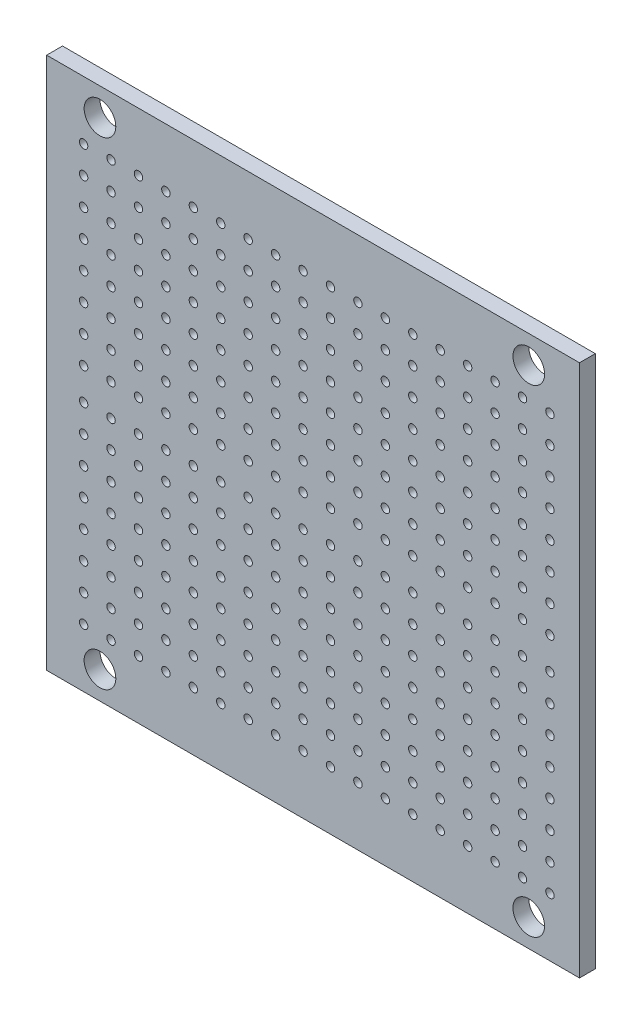
from build123d import *

# Parameters (mm, degrees)
SKETCH1_W           = 50.5
SKETCH1_H           = 50.5
SKETCH1_R           = 1.5
SKETCH1_R_2         = 0.4
BOSS_EXTRUDE1_DEPTH = 1.5
SCALE4_SCALE        = 1.485


with BuildPart() as part:
    # Sketch1 → Boss-Extrude1 (new body)
    with BuildSketch(Plane.XY):
        with Locations((0.25, 0)):
            Rectangle(SKETCH1_W, SKETCH1_H)
        with Locations((-19.95, 22.65)):
            Circle(SKETCH1_R, mode=Mode.SUBTRACT)
        with Locations((20.692322913, 22.65)):
            Circle(SKETCH1_R, mode=Mode.SUBTRACT)
        with Locations((22.7, 19.71)):
            Circle(SKETCH1_R_2, mode=Mode.SUBTRACT)
        with Locations((20.1, 19.71)):
            Circle(SKETCH1_R_2, mode=Mode.SUBTRACT)
        with Locations((17.5, 19.71)):
            Circle(SKETCH1_R_2, mode=Mode.SUBTRACT)
        with Locations((14.9, 19.71)):
            Circle(SKETCH1_R_2, mode=Mode.SUBTRACT)
        with Locations((12.3, 19.71)):
            Circle(SKETCH1_R_2, mode=Mode.SUBTRACT)
        with Locations((9.7, 19.71)):
            Circle(SKETCH1_R_2, mode=Mode.SUBTRACT)
        with Locations((7.1, 19.71)):
            Circle(SKETCH1_R_2, mode=Mode.SUBTRACT)
        with Locations((4.5, 19.71)):
            Circle(SKETCH1_R_2, mode=Mode.SUBTRACT)
        with Locations((1.9, 19.71)):
            Circle(SKETCH1_R_2, mode=Mode.SUBTRACT)
        with Locations((-0.7, 19.71)):
            Circle(SKETCH1_R_2, mode=Mode.SUBTRACT)
        with Locations((-3.3, 19.71)):
            Circle(SKETCH1_R_2, mode=Mode.SUBTRACT)
        with Locations((-5.9, 19.71)):
            Circle(SKETCH1_R_2, mode=Mode.SUBTRACT)
        with Locations((-8.5, 19.71)):
            Circle(SKETCH1_R_2, mode=Mode.SUBTRACT)
        with Locations((-11.1, 19.71)):
            Circle(SKETCH1_R_2, mode=Mode.SUBTRACT)
        with Locations((-13.7, 19.71)):
            Circle(SKETCH1_R_2, mode=Mode.SUBTRACT)
        with Locations((-16.3, 19.71)):
            Circle(SKETCH1_R_2, mode=Mode.SUBTRACT)
        with Locations((-18.9, 19.71)):
            Circle(SKETCH1_R_2, mode=Mode.SUBTRACT)
        with Locations((-21.5, 19.71)):
            Circle(SKETCH1_R_2, mode=Mode.SUBTRACT)
        with Locations((20.1, 17.11)):
            Circle(SKETCH1_R_2, mode=Mode.SUBTRACT)
        with Locations((17.5, 17.11)):
            Circle(SKETCH1_R_2, mode=Mode.SUBTRACT)
        with Locations((14.9, 17.11)):
            Circle(SKETCH1_R_2, mode=Mode.SUBTRACT)
        with Locations((12.3, 17.11)):
            Circle(SKETCH1_R_2, mode=Mode.SUBTRACT)
        with Locations((9.7, 17.11)):
            Circle(SKETCH1_R_2, mode=Mode.SUBTRACT)
        with Locations((7.1, 17.11)):
            Circle(SKETCH1_R_2, mode=Mode.SUBTRACT)
        with Locations((4.5, 17.11)):
            Circle(SKETCH1_R_2, mode=Mode.SUBTRACT)
        with Locations((1.9, 17.11)):
            Circle(SKETCH1_R_2, mode=Mode.SUBTRACT)
        with Locations((-0.7, 17.11)):
            Circle(SKETCH1_R_2, mode=Mode.SUBTRACT)
        with Locations((-3.3, 17.11)):
            Circle(SKETCH1_R_2, mode=Mode.SUBTRACT)
        with Locations((-5.9, 17.11)):
            Circle(SKETCH1_R_2, mode=Mode.SUBTRACT)
        with Locations((-8.5, 17.11)):
            Circle(SKETCH1_R_2, mode=Mode.SUBTRACT)
        with Locations((-11.1, 17.11)):
            Circle(SKETCH1_R_2, mode=Mode.SUBTRACT)
        with Locations((-13.7, 17.11)):
            Circle(SKETCH1_R_2, mode=Mode.SUBTRACT)
        with Locations((-16.3, 17.11)):
            Circle(SKETCH1_R_2, mode=Mode.SUBTRACT)
        with Locations((-18.9, 17.11)):
            Circle(SKETCH1_R_2, mode=Mode.SUBTRACT)
        with Locations((-21.5, 17.11)):
            Circle(SKETCH1_R_2, mode=Mode.SUBTRACT)
        with Locations((20.1, 14.51)):
            Circle(SKETCH1_R_2, mode=Mode.SUBTRACT)
        with Locations((17.5, 14.51)):
            Circle(SKETCH1_R_2, mode=Mode.SUBTRACT)
        with Locations((14.9, 14.51)):
            Circle(SKETCH1_R_2, mode=Mode.SUBTRACT)
        with Locations((12.3, 14.51)):
            Circle(SKETCH1_R_2, mode=Mode.SUBTRACT)
        with Locations((9.7, 14.51)):
            Circle(SKETCH1_R_2, mode=Mode.SUBTRACT)
        with Locations((7.1, 14.51)):
            Circle(SKETCH1_R_2, mode=Mode.SUBTRACT)
        with Locations((4.5, 14.51)):
            Circle(SKETCH1_R_2, mode=Mode.SUBTRACT)
        with Locations((1.9, 14.51)):
            Circle(SKETCH1_R_2, mode=Mode.SUBTRACT)
        with Locations((-0.7, 14.51)):
            Circle(SKETCH1_R_2, mode=Mode.SUBTRACT)
        with Locations((-3.3, 14.51)):
            Circle(SKETCH1_R_2, mode=Mode.SUBTRACT)
        with Locations((-5.9, 14.51)):
            Circle(SKETCH1_R_2, mode=Mode.SUBTRACT)
        with Locations((-8.5, 14.51)):
            Circle(SKETCH1_R_2, mode=Mode.SUBTRACT)
        with Locations((-11.1, 14.51)):
            Circle(SKETCH1_R_2, mode=Mode.SUBTRACT)
        with Locations((-13.7, 14.51)):
            Circle(SKETCH1_R_2, mode=Mode.SUBTRACT)
        with Locations((-16.3, 14.51)):
            Circle(SKETCH1_R_2, mode=Mode.SUBTRACT)
        with Locations((-18.9, 14.51)):
            Circle(SKETCH1_R_2, mode=Mode.SUBTRACT)
        with Locations((-21.5, 14.51)):
            Circle(SKETCH1_R_2, mode=Mode.SUBTRACT)
        with Locations((20.1, 11.91)):
            Circle(SKETCH1_R_2, mode=Mode.SUBTRACT)
        with Locations((17.5, 11.91)):
            Circle(SKETCH1_R_2, mode=Mode.SUBTRACT)
        with Locations((14.9, 11.91)):
            Circle(SKETCH1_R_2, mode=Mode.SUBTRACT)
        with Locations((12.3, 11.91)):
            Circle(SKETCH1_R_2, mode=Mode.SUBTRACT)
        with Locations((9.7, 11.91)):
            Circle(SKETCH1_R_2, mode=Mode.SUBTRACT)
        with Locations((7.1, 11.91)):
            Circle(SKETCH1_R_2, mode=Mode.SUBTRACT)
        with Locations((4.5, 11.91)):
            Circle(SKETCH1_R_2, mode=Mode.SUBTRACT)
        with Locations((1.9, 11.91)):
            Circle(SKETCH1_R_2, mode=Mode.SUBTRACT)
        with Locations((-0.7, 11.91)):
            Circle(SKETCH1_R_2, mode=Mode.SUBTRACT)
        with Locations((-3.3, 11.91)):
            Circle(SKETCH1_R_2, mode=Mode.SUBTRACT)
        with Locations((-5.9, 11.91)):
            Circle(SKETCH1_R_2, mode=Mode.SUBTRACT)
        with Locations((-8.5, 11.91)):
            Circle(SKETCH1_R_2, mode=Mode.SUBTRACT)
        with Locations((-11.1, 11.91)):
            Circle(SKETCH1_R_2, mode=Mode.SUBTRACT)
        with Locations((-13.7, 11.91)):
            Circle(SKETCH1_R_2, mode=Mode.SUBTRACT)
        with Locations((-16.3, 11.91)):
            Circle(SKETCH1_R_2, mode=Mode.SUBTRACT)
        with Locations((-18.9, 11.91)):
            Circle(SKETCH1_R_2, mode=Mode.SUBTRACT)
        with Locations((-21.5, 11.91)):
            Circle(SKETCH1_R_2, mode=Mode.SUBTRACT)
        with Locations((20.1, 9.31)):
            Circle(SKETCH1_R_2, mode=Mode.SUBTRACT)
        with Locations((17.5, 9.31)):
            Circle(SKETCH1_R_2, mode=Mode.SUBTRACT)
        with Locations((14.9, 9.31)):
            Circle(SKETCH1_R_2, mode=Mode.SUBTRACT)
        with Locations((12.3, 9.31)):
            Circle(SKETCH1_R_2, mode=Mode.SUBTRACT)
        with Locations((9.7, 9.31)):
            Circle(SKETCH1_R_2, mode=Mode.SUBTRACT)
        with Locations((7.1, 9.31)):
            Circle(SKETCH1_R_2, mode=Mode.SUBTRACT)
        with Locations((4.5, 9.31)):
            Circle(SKETCH1_R_2, mode=Mode.SUBTRACT)
        with Locations((1.9, 9.31)):
            Circle(SKETCH1_R_2, mode=Mode.SUBTRACT)
        with Locations((-0.7, 9.31)):
            Circle(SKETCH1_R_2, mode=Mode.SUBTRACT)
        with Locations((-3.3, 9.31)):
            Circle(SKETCH1_R_2, mode=Mode.SUBTRACT)
        with Locations((-5.9, 9.31)):
            Circle(SKETCH1_R_2, mode=Mode.SUBTRACT)
        with Locations((-8.5, 9.31)):
            Circle(SKETCH1_R_2, mode=Mode.SUBTRACT)
        with Locations((-11.1, 9.31)):
            Circle(SKETCH1_R_2, mode=Mode.SUBTRACT)
        with Locations((-13.7, 9.31)):
            Circle(SKETCH1_R_2, mode=Mode.SUBTRACT)
        with Locations((-16.3, 9.31)):
            Circle(SKETCH1_R_2, mode=Mode.SUBTRACT)
        with Locations((-18.9, 9.31)):
            Circle(SKETCH1_R_2, mode=Mode.SUBTRACT)
        with Locations((-21.5, 9.31)):
            Circle(SKETCH1_R_2, mode=Mode.SUBTRACT)
        with Locations((20.1, 6.71)):
            Circle(SKETCH1_R_2, mode=Mode.SUBTRACT)
        with Locations((17.5, 6.71)):
            Circle(SKETCH1_R_2, mode=Mode.SUBTRACT)
        with Locations((14.9, 6.71)):
            Circle(SKETCH1_R_2, mode=Mode.SUBTRACT)
        with Locations((12.3, 6.71)):
            Circle(SKETCH1_R_2, mode=Mode.SUBTRACT)
        with Locations((9.7, 6.71)):
            Circle(SKETCH1_R_2, mode=Mode.SUBTRACT)
        with Locations((7.1, 6.71)):
            Circle(SKETCH1_R_2, mode=Mode.SUBTRACT)
        with Locations((4.5, 6.71)):
            Circle(SKETCH1_R_2, mode=Mode.SUBTRACT)
        with Locations((1.9, 6.71)):
            Circle(SKETCH1_R_2, mode=Mode.SUBTRACT)
        with Locations((-0.7, 6.71)):
            Circle(SKETCH1_R_2, mode=Mode.SUBTRACT)
        with Locations((-3.3, 6.71)):
            Circle(SKETCH1_R_2, mode=Mode.SUBTRACT)
        with Locations((-5.9, 6.71)):
            Circle(SKETCH1_R_2, mode=Mode.SUBTRACT)
        with Locations((-8.5, 6.71)):
            Circle(SKETCH1_R_2, mode=Mode.SUBTRACT)
        with Locations((-11.1, 6.71)):
            Circle(SKETCH1_R_2, mode=Mode.SUBTRACT)
        with Locations((-13.7, 6.71)):
            Circle(SKETCH1_R_2, mode=Mode.SUBTRACT)
        with Locations((-16.3, 6.71)):
            Circle(SKETCH1_R_2, mode=Mode.SUBTRACT)
        with Locations((-18.9, 6.71)):
            Circle(SKETCH1_R_2, mode=Mode.SUBTRACT)
        with Locations((-21.5, 6.71)):
            Circle(SKETCH1_R_2, mode=Mode.SUBTRACT)
        with Locations((20.1, 4.11)):
            Circle(SKETCH1_R_2, mode=Mode.SUBTRACT)
        with Locations((17.5, 4.11)):
            Circle(SKETCH1_R_2, mode=Mode.SUBTRACT)
        with Locations((14.9, 4.11)):
            Circle(SKETCH1_R_2, mode=Mode.SUBTRACT)
        with Locations((12.3, 4.11)):
            Circle(SKETCH1_R_2, mode=Mode.SUBTRACT)
        with Locations((9.7, 4.11)):
            Circle(SKETCH1_R_2, mode=Mode.SUBTRACT)
        with Locations((7.1, 4.11)):
            Circle(SKETCH1_R_2, mode=Mode.SUBTRACT)
        with Locations((4.5, 4.11)):
            Circle(SKETCH1_R_2, mode=Mode.SUBTRACT)
        with Locations((1.9, 4.11)):
            Circle(SKETCH1_R_2, mode=Mode.SUBTRACT)
        with Locations((-0.7, 4.11)):
            Circle(SKETCH1_R_2, mode=Mode.SUBTRACT)
        with Locations((-3.3, 4.11)):
            Circle(SKETCH1_R_2, mode=Mode.SUBTRACT)
        with Locations((-5.9, 4.11)):
            Circle(SKETCH1_R_2, mode=Mode.SUBTRACT)
        with Locations((-8.5, 4.11)):
            Circle(SKETCH1_R_2, mode=Mode.SUBTRACT)
        with Locations((-11.1, 4.11)):
            Circle(SKETCH1_R_2, mode=Mode.SUBTRACT)
        with Locations((-13.7, 4.11)):
            Circle(SKETCH1_R_2, mode=Mode.SUBTRACT)
        with Locations((-16.3, 4.11)):
            Circle(SKETCH1_R_2, mode=Mode.SUBTRACT)
        with Locations((-18.9, 4.11)):
            Circle(SKETCH1_R_2, mode=Mode.SUBTRACT)
        with Locations((-21.5, 4.11)):
            Circle(SKETCH1_R_2, mode=Mode.SUBTRACT)
        with Locations((20.1, 1.51)):
            Circle(SKETCH1_R_2, mode=Mode.SUBTRACT)
        with Locations((17.5, 1.51)):
            Circle(SKETCH1_R_2, mode=Mode.SUBTRACT)
        with Locations((14.9, 1.51)):
            Circle(SKETCH1_R_2, mode=Mode.SUBTRACT)
        with Locations((12.3, 1.51)):
            Circle(SKETCH1_R_2, mode=Mode.SUBTRACT)
        with Locations((9.7, 1.51)):
            Circle(SKETCH1_R_2, mode=Mode.SUBTRACT)
        with Locations((7.1, 1.51)):
            Circle(SKETCH1_R_2, mode=Mode.SUBTRACT)
        with Locations((4.5, 1.51)):
            Circle(SKETCH1_R_2, mode=Mode.SUBTRACT)
        with Locations((1.9, 1.51)):
            Circle(SKETCH1_R_2, mode=Mode.SUBTRACT)
        with Locations((-0.7, 1.51)):
            Circle(SKETCH1_R_2, mode=Mode.SUBTRACT)
        with Locations((-3.3, 1.51)):
            Circle(SKETCH1_R_2, mode=Mode.SUBTRACT)
        with Locations((-5.9, 1.51)):
            Circle(SKETCH1_R_2, mode=Mode.SUBTRACT)
        with Locations((-8.5, 1.51)):
            Circle(SKETCH1_R_2, mode=Mode.SUBTRACT)
        with Locations((-11.1, 1.51)):
            Circle(SKETCH1_R_2, mode=Mode.SUBTRACT)
        with Locations((-13.7, 1.51)):
            Circle(SKETCH1_R_2, mode=Mode.SUBTRACT)
        with Locations((-16.3, 1.51)):
            Circle(SKETCH1_R_2, mode=Mode.SUBTRACT)
        with Locations((-18.9, 1.51)):
            Circle(SKETCH1_R_2, mode=Mode.SUBTRACT)
        with Locations((-21.5, 1.51)):
            Circle(SKETCH1_R_2, mode=Mode.SUBTRACT)
        with Locations((22.7, 17.11)):
            Circle(SKETCH1_R_2, mode=Mode.SUBTRACT)
        with Locations((22.7, 14.51)):
            Circle(SKETCH1_R_2, mode=Mode.SUBTRACT)
        with Locations((22.7, 11.91)):
            Circle(SKETCH1_R_2, mode=Mode.SUBTRACT)
        with Locations((22.7, 9.31)):
            Circle(SKETCH1_R_2, mode=Mode.SUBTRACT)
        with Locations((22.7, 6.71)):
            Circle(SKETCH1_R_2, mode=Mode.SUBTRACT)
        with Locations((22.7, 4.11)):
            Circle(SKETCH1_R_2, mode=Mode.SUBTRACT)
        with Locations((22.7, 1.51)):
            Circle(SKETCH1_R_2, mode=Mode.SUBTRACT)
        with Locations((22.7, -1.51)):
            Circle(SKETCH1_R_2, mode=Mode.SUBTRACT)
        with Locations((22.7, -4.11)):
            Circle(SKETCH1_R_2, mode=Mode.SUBTRACT)
        with Locations((22.7, -6.71)):
            Circle(SKETCH1_R_2, mode=Mode.SUBTRACT)
        with Locations((22.7, -9.31)):
            Circle(SKETCH1_R_2, mode=Mode.SUBTRACT)
        with Locations((22.7, -11.91)):
            Circle(SKETCH1_R_2, mode=Mode.SUBTRACT)
        with Locations((22.7, -14.51)):
            Circle(SKETCH1_R_2, mode=Mode.SUBTRACT)
        with Locations((22.7, -17.11)):
            Circle(SKETCH1_R_2, mode=Mode.SUBTRACT)
        with Locations((-21.5, -1.51)):
            Circle(SKETCH1_R_2, mode=Mode.SUBTRACT)
        with Locations((-18.9, -1.51)):
            Circle(SKETCH1_R_2, mode=Mode.SUBTRACT)
        with Locations((-16.3, -1.51)):
            Circle(SKETCH1_R_2, mode=Mode.SUBTRACT)
        with Locations((-13.7, -1.51)):
            Circle(SKETCH1_R_2, mode=Mode.SUBTRACT)
        with Locations((-11.1, -1.51)):
            Circle(SKETCH1_R_2, mode=Mode.SUBTRACT)
        with Locations((-8.5, -1.51)):
            Circle(SKETCH1_R_2, mode=Mode.SUBTRACT)
        with Locations((-5.9, -1.51)):
            Circle(SKETCH1_R_2, mode=Mode.SUBTRACT)
        with Locations((-3.3, -1.51)):
            Circle(SKETCH1_R_2, mode=Mode.SUBTRACT)
        with Locations((-0.7, -1.51)):
            Circle(SKETCH1_R_2, mode=Mode.SUBTRACT)
        with Locations((1.9, -1.51)):
            Circle(SKETCH1_R_2, mode=Mode.SUBTRACT)
        with Locations((4.5, -1.51)):
            Circle(SKETCH1_R_2, mode=Mode.SUBTRACT)
        with Locations((7.1, -1.51)):
            Circle(SKETCH1_R_2, mode=Mode.SUBTRACT)
        with Locations((9.7, -1.51)):
            Circle(SKETCH1_R_2, mode=Mode.SUBTRACT)
        with Locations((12.3, -1.51)):
            Circle(SKETCH1_R_2, mode=Mode.SUBTRACT)
        with Locations((14.9, -1.51)):
            Circle(SKETCH1_R_2, mode=Mode.SUBTRACT)
        with Locations((17.5, -1.51)):
            Circle(SKETCH1_R_2, mode=Mode.SUBTRACT)
        with Locations((20.1, -1.51)):
            Circle(SKETCH1_R_2, mode=Mode.SUBTRACT)
        with Locations((-21.5, -4.11)):
            Circle(SKETCH1_R_2, mode=Mode.SUBTRACT)
        with Locations((-18.9, -4.11)):
            Circle(SKETCH1_R_2, mode=Mode.SUBTRACT)
        with Locations((-16.3, -4.11)):
            Circle(SKETCH1_R_2, mode=Mode.SUBTRACT)
        with Locations((-13.7, -4.11)):
            Circle(SKETCH1_R_2, mode=Mode.SUBTRACT)
        with Locations((-11.1, -4.11)):
            Circle(SKETCH1_R_2, mode=Mode.SUBTRACT)
        with Locations((-8.5, -4.11)):
            Circle(SKETCH1_R_2, mode=Mode.SUBTRACT)
        with Locations((-5.9, -4.11)):
            Circle(SKETCH1_R_2, mode=Mode.SUBTRACT)
        with Locations((-3.3, -4.11)):
            Circle(SKETCH1_R_2, mode=Mode.SUBTRACT)
        with Locations((-0.7, -4.11)):
            Circle(SKETCH1_R_2, mode=Mode.SUBTRACT)
        with Locations((1.9, -4.11)):
            Circle(SKETCH1_R_2, mode=Mode.SUBTRACT)
        with Locations((4.5, -4.11)):
            Circle(SKETCH1_R_2, mode=Mode.SUBTRACT)
        with Locations((7.1, -4.11)):
            Circle(SKETCH1_R_2, mode=Mode.SUBTRACT)
        with Locations((9.7, -4.11)):
            Circle(SKETCH1_R_2, mode=Mode.SUBTRACT)
        with Locations((12.3, -4.11)):
            Circle(SKETCH1_R_2, mode=Mode.SUBTRACT)
        with Locations((14.9, -4.11)):
            Circle(SKETCH1_R_2, mode=Mode.SUBTRACT)
        with Locations((17.5, -4.11)):
            Circle(SKETCH1_R_2, mode=Mode.SUBTRACT)
        with Locations((20.1, -4.11)):
            Circle(SKETCH1_R_2, mode=Mode.SUBTRACT)
        with Locations((-21.5, -6.71)):
            Circle(SKETCH1_R_2, mode=Mode.SUBTRACT)
        with Locations((-18.9, -6.71)):
            Circle(SKETCH1_R_2, mode=Mode.SUBTRACT)
        with Locations((-16.3, -6.71)):
            Circle(SKETCH1_R_2, mode=Mode.SUBTRACT)
        with Locations((-13.7, -6.71)):
            Circle(SKETCH1_R_2, mode=Mode.SUBTRACT)
        with Locations((-11.1, -6.71)):
            Circle(SKETCH1_R_2, mode=Mode.SUBTRACT)
        with Locations((-8.5, -6.71)):
            Circle(SKETCH1_R_2, mode=Mode.SUBTRACT)
        with Locations((-5.9, -6.71)):
            Circle(SKETCH1_R_2, mode=Mode.SUBTRACT)
        with Locations((-3.3, -6.71)):
            Circle(SKETCH1_R_2, mode=Mode.SUBTRACT)
        with Locations((-0.7, -6.71)):
            Circle(SKETCH1_R_2, mode=Mode.SUBTRACT)
        with Locations((1.9, -6.71)):
            Circle(SKETCH1_R_2, mode=Mode.SUBTRACT)
        with Locations((4.5, -6.71)):
            Circle(SKETCH1_R_2, mode=Mode.SUBTRACT)
        with Locations((7.1, -6.71)):
            Circle(SKETCH1_R_2, mode=Mode.SUBTRACT)
        with Locations((9.7, -6.71)):
            Circle(SKETCH1_R_2, mode=Mode.SUBTRACT)
        with Locations((12.3, -6.71)):
            Circle(SKETCH1_R_2, mode=Mode.SUBTRACT)
        with Locations((14.9, -6.71)):
            Circle(SKETCH1_R_2, mode=Mode.SUBTRACT)
        with Locations((17.5, -6.71)):
            Circle(SKETCH1_R_2, mode=Mode.SUBTRACT)
        with Locations((20.1, -6.71)):
            Circle(SKETCH1_R_2, mode=Mode.SUBTRACT)
        with Locations((-21.5, -9.31)):
            Circle(SKETCH1_R_2, mode=Mode.SUBTRACT)
        with Locations((-18.9, -9.31)):
            Circle(SKETCH1_R_2, mode=Mode.SUBTRACT)
        with Locations((-16.3, -9.31)):
            Circle(SKETCH1_R_2, mode=Mode.SUBTRACT)
        with Locations((-13.7, -9.31)):
            Circle(SKETCH1_R_2, mode=Mode.SUBTRACT)
        with Locations((-11.1, -9.31)):
            Circle(SKETCH1_R_2, mode=Mode.SUBTRACT)
        with Locations((-8.5, -9.31)):
            Circle(SKETCH1_R_2, mode=Mode.SUBTRACT)
        with Locations((-5.9, -9.31)):
            Circle(SKETCH1_R_2, mode=Mode.SUBTRACT)
        with Locations((-3.3, -9.31)):
            Circle(SKETCH1_R_2, mode=Mode.SUBTRACT)
        with Locations((-0.7, -9.31)):
            Circle(SKETCH1_R_2, mode=Mode.SUBTRACT)
        with Locations((1.9, -9.31)):
            Circle(SKETCH1_R_2, mode=Mode.SUBTRACT)
        with Locations((4.5, -9.31)):
            Circle(SKETCH1_R_2, mode=Mode.SUBTRACT)
        with Locations((7.1, -9.31)):
            Circle(SKETCH1_R_2, mode=Mode.SUBTRACT)
        with Locations((9.7, -9.31)):
            Circle(SKETCH1_R_2, mode=Mode.SUBTRACT)
        with Locations((12.3, -9.31)):
            Circle(SKETCH1_R_2, mode=Mode.SUBTRACT)
        with Locations((14.9, -9.31)):
            Circle(SKETCH1_R_2, mode=Mode.SUBTRACT)
        with Locations((17.5, -9.31)):
            Circle(SKETCH1_R_2, mode=Mode.SUBTRACT)
        with Locations((20.1, -9.31)):
            Circle(SKETCH1_R_2, mode=Mode.SUBTRACT)
        with Locations((-21.5, -11.91)):
            Circle(SKETCH1_R_2, mode=Mode.SUBTRACT)
        with Locations((-18.9, -11.91)):
            Circle(SKETCH1_R_2, mode=Mode.SUBTRACT)
        with Locations((-16.3, -11.91)):
            Circle(SKETCH1_R_2, mode=Mode.SUBTRACT)
        with Locations((-13.7, -11.91)):
            Circle(SKETCH1_R_2, mode=Mode.SUBTRACT)
        with Locations((-11.1, -11.91)):
            Circle(SKETCH1_R_2, mode=Mode.SUBTRACT)
        with Locations((-8.5, -11.91)):
            Circle(SKETCH1_R_2, mode=Mode.SUBTRACT)
        with Locations((-5.9, -11.91)):
            Circle(SKETCH1_R_2, mode=Mode.SUBTRACT)
        with Locations((-3.3, -11.91)):
            Circle(SKETCH1_R_2, mode=Mode.SUBTRACT)
        with Locations((-0.7, -11.91)):
            Circle(SKETCH1_R_2, mode=Mode.SUBTRACT)
        with Locations((1.9, -11.91)):
            Circle(SKETCH1_R_2, mode=Mode.SUBTRACT)
        with Locations((4.5, -11.91)):
            Circle(SKETCH1_R_2, mode=Mode.SUBTRACT)
        with Locations((7.1, -11.91)):
            Circle(SKETCH1_R_2, mode=Mode.SUBTRACT)
        with Locations((9.7, -11.91)):
            Circle(SKETCH1_R_2, mode=Mode.SUBTRACT)
        with Locations((12.3, -11.91)):
            Circle(SKETCH1_R_2, mode=Mode.SUBTRACT)
        with Locations((14.9, -11.91)):
            Circle(SKETCH1_R_2, mode=Mode.SUBTRACT)
        with Locations((17.5, -11.91)):
            Circle(SKETCH1_R_2, mode=Mode.SUBTRACT)
        with Locations((20.1, -11.91)):
            Circle(SKETCH1_R_2, mode=Mode.SUBTRACT)
        with Locations((-21.5, -14.51)):
            Circle(SKETCH1_R_2, mode=Mode.SUBTRACT)
        with Locations((-18.9, -14.51)):
            Circle(SKETCH1_R_2, mode=Mode.SUBTRACT)
        with Locations((-16.3, -14.51)):
            Circle(SKETCH1_R_2, mode=Mode.SUBTRACT)
        with Locations((-13.7, -14.51)):
            Circle(SKETCH1_R_2, mode=Mode.SUBTRACT)
        with Locations((-11.1, -14.51)):
            Circle(SKETCH1_R_2, mode=Mode.SUBTRACT)
        with Locations((-8.5, -14.51)):
            Circle(SKETCH1_R_2, mode=Mode.SUBTRACT)
        with Locations((-5.9, -14.51)):
            Circle(SKETCH1_R_2, mode=Mode.SUBTRACT)
        with Locations((-3.3, -14.51)):
            Circle(SKETCH1_R_2, mode=Mode.SUBTRACT)
        with Locations((-0.7, -14.51)):
            Circle(SKETCH1_R_2, mode=Mode.SUBTRACT)
        with Locations((1.9, -14.51)):
            Circle(SKETCH1_R_2, mode=Mode.SUBTRACT)
        with Locations((4.5, -14.51)):
            Circle(SKETCH1_R_2, mode=Mode.SUBTRACT)
        with Locations((7.1, -14.51)):
            Circle(SKETCH1_R_2, mode=Mode.SUBTRACT)
        with Locations((9.7, -14.51)):
            Circle(SKETCH1_R_2, mode=Mode.SUBTRACT)
        with Locations((12.3, -14.51)):
            Circle(SKETCH1_R_2, mode=Mode.SUBTRACT)
        with Locations((14.9, -14.51)):
            Circle(SKETCH1_R_2, mode=Mode.SUBTRACT)
        with Locations((17.5, -14.51)):
            Circle(SKETCH1_R_2, mode=Mode.SUBTRACT)
        with Locations((20.1, -14.51)):
            Circle(SKETCH1_R_2, mode=Mode.SUBTRACT)
        with Locations((-21.5, -17.11)):
            Circle(SKETCH1_R_2, mode=Mode.SUBTRACT)
        with Locations((-18.9, -17.11)):
            Circle(SKETCH1_R_2, mode=Mode.SUBTRACT)
        with Locations((-16.3, -17.11)):
            Circle(SKETCH1_R_2, mode=Mode.SUBTRACT)
        with Locations((-13.7, -17.11)):
            Circle(SKETCH1_R_2, mode=Mode.SUBTRACT)
        with Locations((-11.1, -17.11)):
            Circle(SKETCH1_R_2, mode=Mode.SUBTRACT)
        with Locations((-8.5, -17.11)):
            Circle(SKETCH1_R_2, mode=Mode.SUBTRACT)
        with Locations((-5.9, -17.11)):
            Circle(SKETCH1_R_2, mode=Mode.SUBTRACT)
        with Locations((-3.3, -17.11)):
            Circle(SKETCH1_R_2, mode=Mode.SUBTRACT)
        with Locations((-0.7, -17.11)):
            Circle(SKETCH1_R_2, mode=Mode.SUBTRACT)
        with Locations((1.9, -17.11)):
            Circle(SKETCH1_R_2, mode=Mode.SUBTRACT)
        with Locations((4.5, -17.11)):
            Circle(SKETCH1_R_2, mode=Mode.SUBTRACT)
        with Locations((7.1, -17.11)):
            Circle(SKETCH1_R_2, mode=Mode.SUBTRACT)
        with Locations((9.7, -17.11)):
            Circle(SKETCH1_R_2, mode=Mode.SUBTRACT)
        with Locations((12.3, -17.11)):
            Circle(SKETCH1_R_2, mode=Mode.SUBTRACT)
        with Locations((14.9, -17.11)):
            Circle(SKETCH1_R_2, mode=Mode.SUBTRACT)
        with Locations((17.5, -17.11)):
            Circle(SKETCH1_R_2, mode=Mode.SUBTRACT)
        with Locations((20.1, -17.11)):
            Circle(SKETCH1_R_2, mode=Mode.SUBTRACT)
        with Locations((-21.5, -19.71)):
            Circle(SKETCH1_R_2, mode=Mode.SUBTRACT)
        with Locations((-18.9, -19.71)):
            Circle(SKETCH1_R_2, mode=Mode.SUBTRACT)
        with Locations((-16.3, -19.71)):
            Circle(SKETCH1_R_2, mode=Mode.SUBTRACT)
        with Locations((-13.7, -19.71)):
            Circle(SKETCH1_R_2, mode=Mode.SUBTRACT)
        with Locations((-11.1, -19.71)):
            Circle(SKETCH1_R_2, mode=Mode.SUBTRACT)
        with Locations((-8.5, -19.71)):
            Circle(SKETCH1_R_2, mode=Mode.SUBTRACT)
        with Locations((-5.9, -19.71)):
            Circle(SKETCH1_R_2, mode=Mode.SUBTRACT)
        with Locations((-3.3, -19.71)):
            Circle(SKETCH1_R_2, mode=Mode.SUBTRACT)
        with Locations((-0.7, -19.71)):
            Circle(SKETCH1_R_2, mode=Mode.SUBTRACT)
        with Locations((1.9, -19.71)):
            Circle(SKETCH1_R_2, mode=Mode.SUBTRACT)
        with Locations((4.5, -19.71)):
            Circle(SKETCH1_R_2, mode=Mode.SUBTRACT)
        with Locations((7.1, -19.71)):
            Circle(SKETCH1_R_2, mode=Mode.SUBTRACT)
        with Locations((9.7, -19.71)):
            Circle(SKETCH1_R_2, mode=Mode.SUBTRACT)
        with Locations((12.3, -19.71)):
            Circle(SKETCH1_R_2, mode=Mode.SUBTRACT)
        with Locations((14.9, -19.71)):
            Circle(SKETCH1_R_2, mode=Mode.SUBTRACT)
        with Locations((17.5, -19.71)):
            Circle(SKETCH1_R_2, mode=Mode.SUBTRACT)
        with Locations((20.1, -19.71)):
            Circle(SKETCH1_R_2, mode=Mode.SUBTRACT)
        with Locations((22.7, -19.71)):
            Circle(SKETCH1_R_2, mode=Mode.SUBTRACT)
        with Locations((20.692322913, -22.65)):
            Circle(SKETCH1_R, mode=Mode.SUBTRACT)
        with Locations((-19.95, -22.65)):
            Circle(SKETCH1_R, mode=Mode.SUBTRACT)
    extrude(amount=BOSS_EXTRUDE1_DEPTH)


with BuildPart() as part_1:
    # Scale4: scaled about (0.22724503, 0, 0.75)
    add(part.part.scale(SCALE4_SCALE).moved(Location((-0.11021384, 0, -0.36375))))


solid = part_1.part
